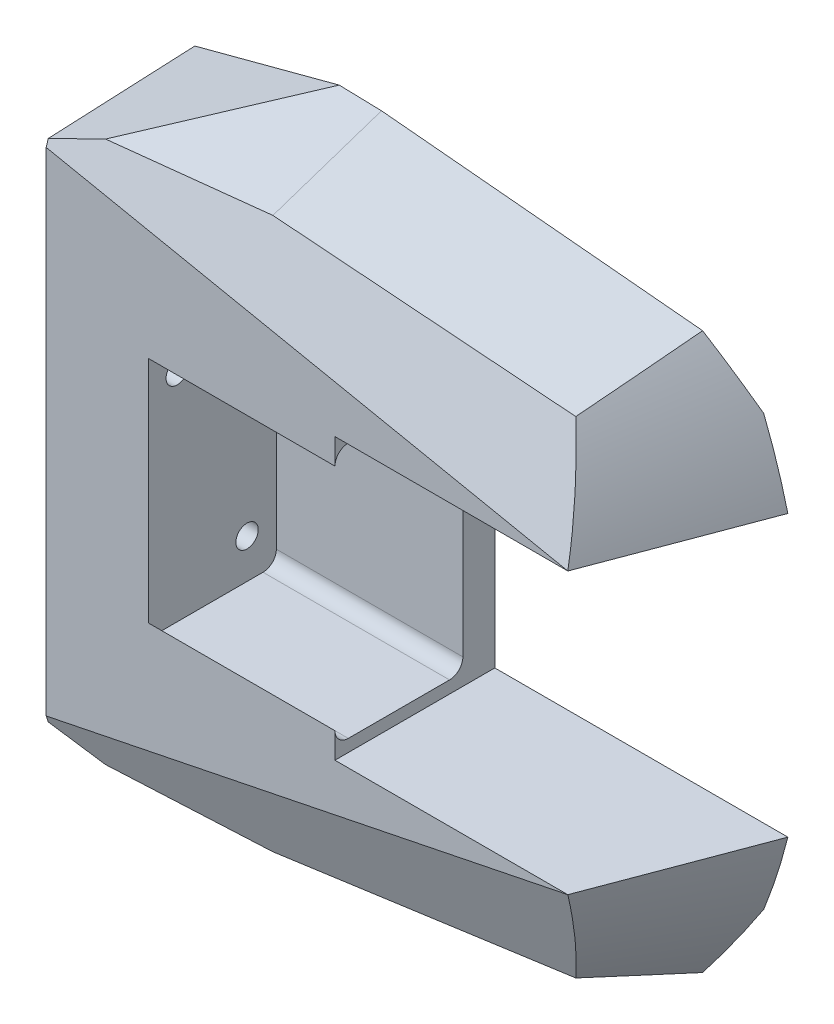
from build123d import *

# Parameters (mm, degrees)
BOSS_EXTRUDE1_DEPTH             = 30
SKETCH3_W                       = 30
SKETCH3_H                       = 52.601373674
CUT_EXTRUDE1_DEPTH              = 20
DRAFT1_ANGLE                    = 20
CUT_EXTRUDE2_DEPTH              = 5
CUT_EXTRUDE3_DEPTH              = 5
M6X1_0_TAPPED_HOLE1_D           = 5
M6X1_0_TAPPED_HOLE1_DEPTH       = 10
M6X1_0_TAPPED_HOLE1_TIP         = 1.502151548
CUT_REVOLVE1_ANGLE              = 20
CUT_REVOLVE2_ANGLE              = 20
CUT_REVOLVE3_ANGLE              = 20
CUT_REVOLVE4_ANGLE              = 20
CUT_EXTRUDE4_DEPTH              = 35
M5X0_8_TAPPED_HOLE1_D           = 4.2
SKETCH19_W                      = 47.516094142
SKETCH19_H                      = 117.781056104
CUT_REVOLVE5_ANGLE              = 4
M5X0_8_TAPPED_HOLE2_D           = 4.2
M5X0_8_TAPPED_HOLE2_DEPTH       = 10
M5X0_8_TAPPED_HOLE2_CSINK_D     = 10.5
M5X0_8_TAPPED_HOLE2_CSINK_ANGLE = 90
M5X0_8_TAPPED_HOLE2_TIP         = 1.2618073


with BuildPart() as part:
    # Sketch2 → Boss-Extrude1 (new body)
    with BuildSketch(Plane.XY):
        with BuildLine():
            Line((-41.221662469, 50), (-50, 46.630311934))
            Line((-50, 46.630311934), (-50, -46.630311934))
            Line((-50, -46.630311934), (-41.221662469, -50))
            Line((-41.221662469, -50), (-10.163742616, -50))
            Line((-10.163742616, -50), (43.420662363, -43.420662363))
            ThreePointArc((43.420662363, -43.420662363), (47.113322701, -35.015547326), (50, -26.300686837))
            Line((50, -26.300686837), (26.300686837, -26.300686837))
            Line((26.300686837, -26.300686837), (26.300686837, 26.300686837))
            Line((26.300686837, 26.300686837), (50, 26.300686837))
            ThreePointArc((50, 26.300686837), (47.113322701, 35.015547326), (43.420662363, 43.420662363))
            Line((43.420662363, 43.420662363), (-10.163742616, 50))
            Line((-10.163742616, 50), (-41.221662469, 50))
        make_face()
    extrude(amount=BOSS_EXTRUDE1_DEPTH)

    # Sketch3 → Cut-Extrude1 (cut)
    with BuildSketch(Plane(origin=(26.300686837, 0, 0), x_dir=(0, 0, -1), z_dir=(1, 0, 0))):
        with Locations((-15, 0)):
            Rectangle(SKETCH3_W, SKETCH3_H)
    extrude(amount=-CUT_EXTRUDE1_DEPTH, mode=Mode.SUBTRACT)

    # Draft1
    draft1_faces = [part.faces().sort_by_distance(p)[0] for p in [
        (-25.692702542, 50, 15),
        (16.628459874, 46.710331182, 15),
        (47.113322701, 35.015547326, 15),
        (47.113322701, -35.015547326, 15),
        (-25.692702542, -50, 15),
        (16.628459874, -46.710331182, 15),
    ]]
    draft(draft1_faces, Plane.XY.offset(30), DRAFT1_ANGLE)

    # Sketch5 → Cut-Extrude2 (cut)
    with BuildSketch(Plane.ZY.offset(50)):
        with BuildLine():
            Line((0, 42), (23, 42))
            ThreePointArc((23, 42), (26.535533906, 40.535533906), (28, 37))
            Line((28, 37), (28, -37))
            ThreePointArc((28, -37), (26.535533906, -40.535533906), (23, -42))
            Line((23, -42), (0, -42))
            Line((0, -42), (0, 42))
        make_face()
    extrude(amount=-CUT_EXTRUDE2_DEPTH, mode=Mode.SUBTRACT)

    # Sketch6 → Cut-Extrude3 (cut)
    with BuildSketch(Plane(origin=(0, 0, 0), x_dir=(-1, 0, 0), z_dir=(0, 0, -1))):
        with BuildLine():
            Line((45, 42), (10, 42))
            ThreePointArc((10, 42), (6.464466094, 40.535533906), (5, 37))
            Line((5, 37), (5, -37))
            ThreePointArc((5, -37), (6.464466094, -40.535533906), (10, -42))
            Line((10, -42), (45, -42))
            Line((45, -42), (45, 42))
        make_face()
    extrude(amount=-CUT_EXTRUDE3_DEPTH, mode=Mode.SUBTRACT)

    # M6x1.0 Tapped Hole1
    with Locations(Plane(origin=(0, 0, 5), x_dir=(-1, 0, 0), z_dir=(0, 0, -1))):
        with Locations((29.9, 29.895651858), (29.9, -29.895651858)):
            Hole(M6X1_0_TAPPED_HOLE1_D / 2, depth=M6X1_0_TAPPED_HOLE1_DEPTH)
            with Locations((0, 0, -(M6X1_0_TAPPED_HOLE1_DEPTH + M6X1_0_TAPPED_HOLE1_TIP / 2))):  # 118° drill point
                Cone(0, M6X1_0_TAPPED_HOLE1_D / 2, M6X1_0_TAPPED_HOLE1_TIP, mode=Mode.SUBTRACT)

    # Sketch9 → Cut-Revolve1 (revolve, cut)
    with BuildSketch(Plane(origin=(0, 0, 0), x_dir=(-1, 0, 0), z_dir=(0, 0, -1))):
        with BuildLine():
            Line((50, 46.630311934), (-56.76790933, 40.30398391))
            ThreePointArc((-56.76790933, 40.30398391), (-54.419330105, 48.540812289), (-51.472316128, 56.582968389))
            Line((-51.472316128, 56.582968389), (18.167108014, 64.912852718))
            Line((18.167108014, 64.912852718), (50, 46.630311934))
        make_face()
    revolve(axis=Axis((-50, 46.630311934, 0), (0.9982491449473906, -0.0591493416007627, 0)), revolution_arc=CUT_REVOLVE1_ANGLE, mode=Mode.SUBTRACT)

    # Sketch11 → Cut-Revolve2 (revolve, cut)
    with BuildSketch(Plane(origin=(0, 0, 0), x_dir=(-1, 0, 0), z_dir=(0, 0, -1))):
        with BuildLine():
            Line((50, -46.630311934), (-56.76790933, -40.30398391))
            ThreePointArc((-56.76790933, -40.30398391), (-55.407295575, -48.597993011), (-53.453959647, -56.772730652))
            Line((-53.453959647, -56.772730652), (21.223580117, -65.428953237))
            Line((21.223580117, -65.428953237), (50, -46.630311934))
        make_face()
    revolve(axis=Axis((-50, -46.630311934, 0), (-0.9982491449473906, -0.05914934160076277, 0)), revolution_arc=CUT_REVOLVE2_ANGLE, mode=Mode.SUBTRACT)

    # Sketch13 → Cut-Revolve3 (revolve, cut)
    with BuildSketch(Plane.XY.offset(30)):
        Polygon((-50, 46.630311934), (50, 26.300686837), (49.446951964, 52.159989852), (-50, 58.994858097), align=None)
    revolve(axis=Axis((-50, 46.630311934, 30), (-0.9799545689980745, 0.1992210899975155, 0)), revolution_arc=CUT_REVOLVE3_ANGLE, mode=Mode.SUBTRACT)

    # Sketch14 → Cut-Revolve4 (revolve, cut)
    with BuildSketch(Plane.XY.offset(30)):
        Polygon((50, -26.300686837), (49.446951964, -52.159989852), (-50, -58.995311934), (-50, -46.630311934), align=None)
    revolve(axis=Axis((50, -26.300686837, 30), (0.9799545689980745, 0.1992210899975155, 0)), revolution_arc=CUT_REVOLVE4_ANGLE, mode=Mode.SUBTRACT)

    # Sketch15 → Cut-Extrude4 (cut)
    with BuildSketch(Plane(origin=(6.300686837, 0, 0), x_dir=(0, 0, -1), z_dir=(1, 0, 0))):
        with BuildLine():
            Line((-30, 0), (-30, -21.5))
            ThreePointArc((-30, -21.5), (-29.267766953, -23.267766953), (-27.5, -24))
            Line((-27.5, -24), (-8.5, -24))
            ThreePointArc((-8.5, -24), (-6.732233047, -23.267766953), (-6, -21.5))
            Line((-6, -21.5), (-6, 21.5))
            ThreePointArc((-6, 21.5), (-6.732233047, 23.267766953), (-8.5, 24))
            Line((-8.5, 24), (-27.5, 24))
            ThreePointArc((-27.5, 24), (-29.267766953, 23.267766953), (-30, 21.5))
            Line((-30, 21.5), (-30, 0))
        make_face()
    extrude(amount=-CUT_EXTRUDE4_DEPTH, mode=Mode.SUBTRACT)

    # M5x0.8 Tapped Hole1 (through all)
    with Locations(Plane(origin=(-28.699313163, 0, 0), x_dir=(0, 0, -1), z_dir=(1, 0, 0))):
        with Locations((-11.497988924, -16.605361405), (-24.602011076, 16.605361405)):
            Hole(M5X0_8_TAPPED_HOLE1_D / 2)

    # Sketch19 → Cut-Revolve5 (revolve, cut)
    with BuildSketch(Plane.ZY.offset(50)):
        with Locations((23.758047071, 0)):
            Rectangle(SKETCH19_W, SKETCH19_H)
    revolve(axis=Axis((-50, 58.890528052, 0), (0, 1, 0)), revolution_arc=CUT_REVOLVE5_ANGLE, mode=Mode.SUBTRACT)

    # M5x0.8 Tapped Hole2
    with Locations(Plane(origin=(0, 0, 0), x_dir=(-1, 0, 0), z_dir=(0, 0, -1))):
        with Locations((-50.268656574, 33.379143774), (-50.268656574, -33.379143774), (-36.268656574, -33.379143774), (-22.268656574, -33.379143774), (-36.268656574, 33.379143774), (-22.268656574, 33.379143774)):
            CounterSinkHole(M5X0_8_TAPPED_HOLE2_D / 2, M5X0_8_TAPPED_HOLE2_CSINK_D / 2, depth=M5X0_8_TAPPED_HOLE2_DEPTH, counter_sink_angle=M5X0_8_TAPPED_HOLE2_CSINK_ANGLE)
            with Locations((0, 0, -(M5X0_8_TAPPED_HOLE2_DEPTH + M5X0_8_TAPPED_HOLE2_TIP / 2))):  # 118° drill point
                Cone(0, M5X0_8_TAPPED_HOLE2_D / 2, M5X0_8_TAPPED_HOLE2_TIP, mode=Mode.SUBTRACT)


solid = part.part
